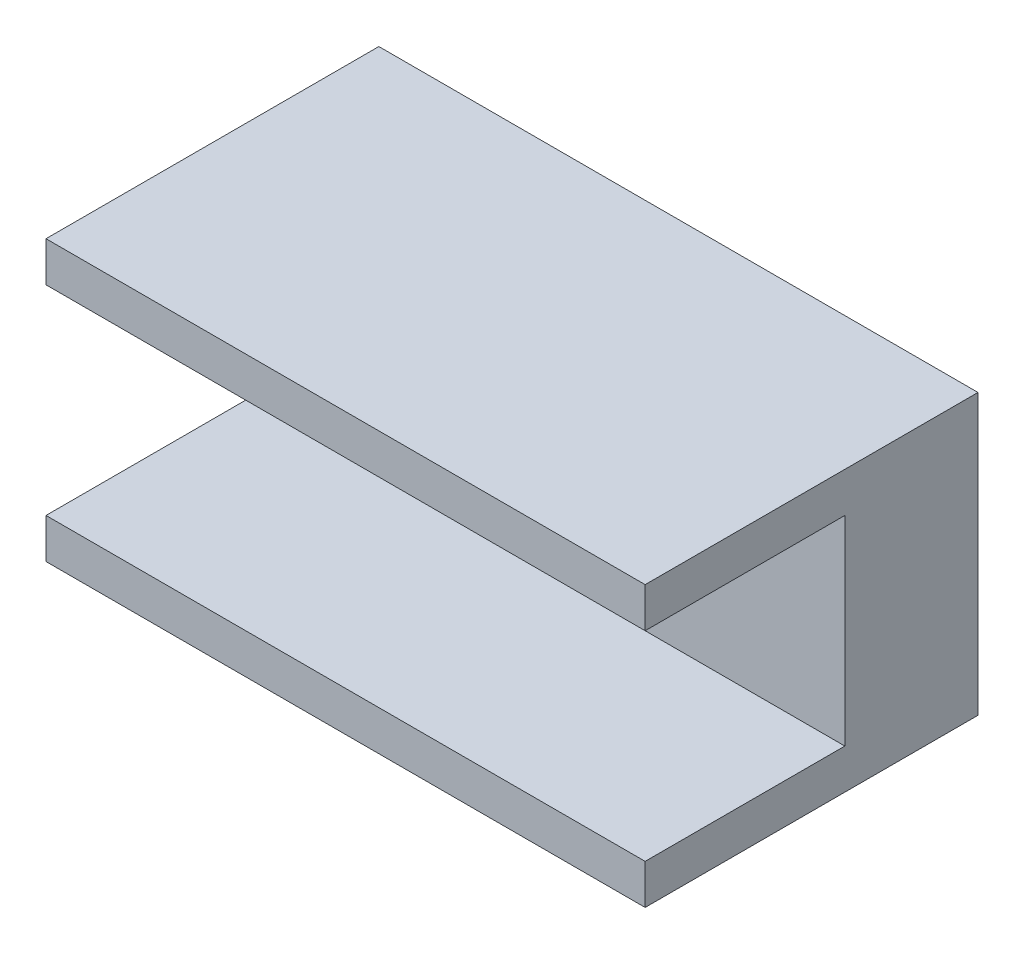
from build123d import *

# Parameters (mm, degrees)
SKETCH_1_W          = 45
SKETCH_1_H          = 21
EXTRUDE_1_DEPTH     = 25
SKETCH_2_W          = 45
SKETCH_2_H          = 15
CUT_EXTRUDE_1_DEPTH = 15


with BuildPart() as part:
    # 草图1 → 凸台-拉伸1 (new body)
    with BuildSketch(Plane.XY):
        with Locations((-120.87955632, 408.309627253)):
            Rectangle(SKETCH_1_W, SKETCH_1_H)
    extrude(amount=EXTRUDE_1_DEPTH)

    # 草图2 → 切除-拉伸1 (cut)
    with BuildSketch(Plane.XY.offset(25)):
        with Locations((-120.87955632, 408.309627253)):
            Rectangle(SKETCH_2_W, SKETCH_2_H)
    extrude(amount=-CUT_EXTRUDE_1_DEPTH, mode=Mode.SUBTRACT)


solid = part.part
